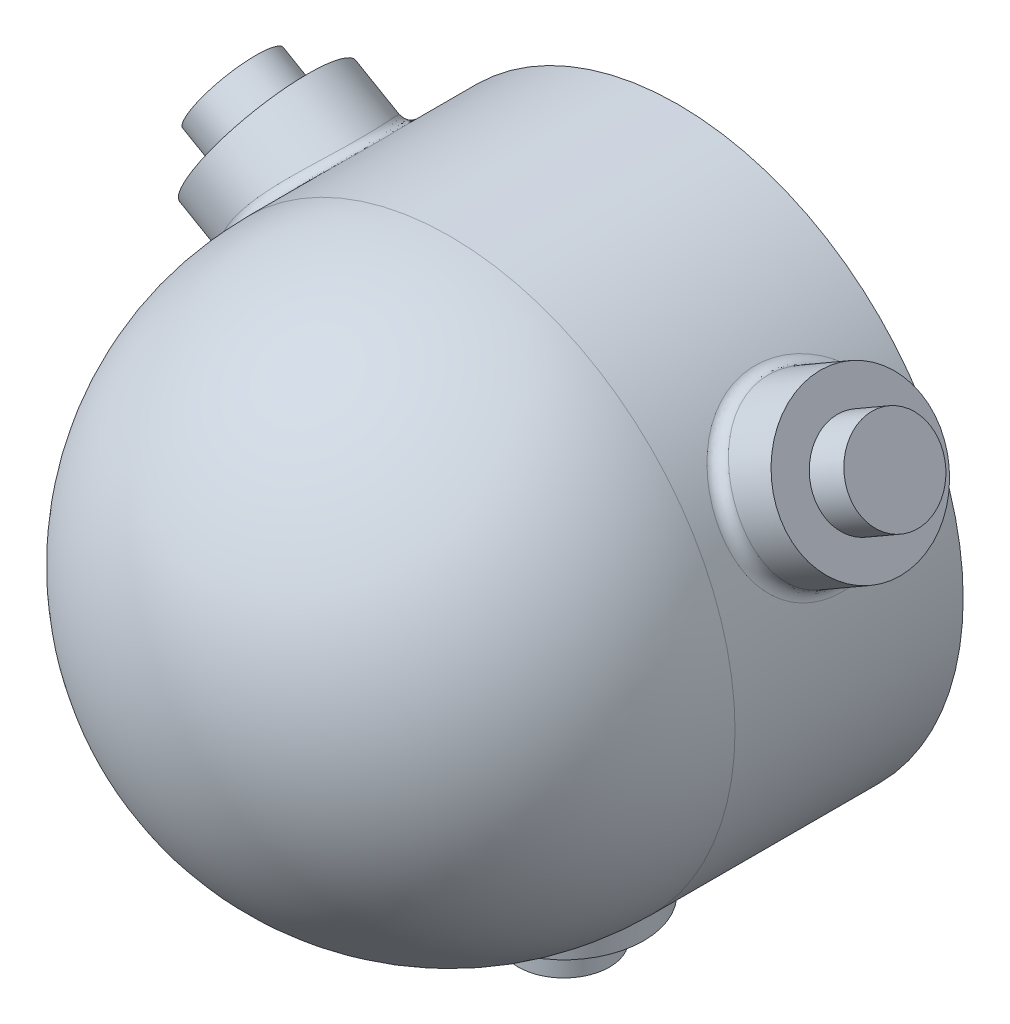
from build123d import *

# Parameters (mm, degrees)
SKETCH1_R           = 25
BOSS_EXTRUDE1_DEPTH = 20
SKETCH2_R           = 7
BOSS_EXTRUDE4_DEPTH = 5
SKETCH5_R           = 12.5
CUT_EXTRUDE2_DEPTH  = 10
REVOLVE1_ANGLE      = 180
SKETCH7_R           = 4
BOSS_EXTRUDE5_DEPTH = 3.5
CIRPATTERN1_COUNT   = 3
FILLET1_R           = 1
FILLET2_R           = 1
FILLET3_R           = 1


with BuildPart() as part:
    # Sketch1 → Boss-Extrude1 (new body)
    with BuildSketch(Plane.XY):
        Circle(SKETCH1_R)
    extrude(amount=BOSS_EXTRUDE1_DEPTH)

    # Sketch2 → Boss-Extrude4 (add, symmetric)
    with BuildSketch(Plane(origin=(-21.650635095, 12.5, 0), x_dir=(0, 0, -1), z_dir=(-0.866025404, 0.5, 0))):
        with Locations((-10, 0)):
            Circle(SKETCH2_R)
    boss_extrude4 = extrude(amount=BOSS_EXTRUDE4_DEPTH, both=True)

    # Sketch5 → Cut-Extrude2 (cut)
    with BuildSketch(Plane(origin=(0, 0, 0), x_dir=(-1, 0, 0), z_dir=(0, 0, -1))):
        Circle(SKETCH5_R)
    extrude(amount=-CUT_EXTRUDE2_DEPTH, mode=Mode.SUBTRACT)

    # Sketch6 → Revolve1 (revolve)
    with BuildSketch(Plane.XY.offset(20)):
        with BuildLine():
            Line((0, -25), (0, 25))
            ThreePointArc((0, 25), (-17.67766953, 17.67766953), (-25, 0))
            ThreePointArc((-25, 0), (-17.67766953, -17.67766953), (0, -25))
        make_face()
    revolve(axis=Axis((0, -25, 20), (0, 1, 0)), revolution_arc=REVOLVE1_ANGLE)

    # Sketch7 → Boss-Extrude5 (add)
    with BuildSketch(Plane(origin=(-25.980762114, 15, 0), x_dir=(0, 0, 1), z_dir=(-0.866025404, 0.5, 0))):
        with Locations((10, 0)):
            Circle(SKETCH7_R)
    boss_extrude5 = extrude(amount=BOSS_EXTRUDE5_DEPTH)

    # CirPattern1: Boss-Extrude4, Boss-Extrude5 ×3 about axis
    cirpattern1_axis = Axis((0, 0, 0), (0, 0, 1))
    for i in range(1, CIRPATTERN1_COUNT):
        add(boss_extrude4.rotate(cirpattern1_axis, i * 360 / CIRPATTERN1_COUNT))
        add(boss_extrude5.rotate(cirpattern1_axis, i * 360 / CIRPATTERN1_COUNT))

    # Fillet1
    fillet1_edges = [part.edges().sort_by_distance(p)[0] for p in [
        (21.650635066, 12.499999983, 17.000000008),
    ]]
    fillet(fillet1_edges, radius=FILLET1_R)

    # Fillet2
    fillet2_edges = [part.edges().sort_by_distance(p)[0] for p in [
        (-21.650635066, 12.499999983, 17.000000008),
    ]]
    fillet(fillet2_edges, radius=FILLET2_R)

    # Fillet3
    fillet3_edges = [part.edges().sort_by_distance(p)[0] for p in [
        (0, -24.999999967, 17.000000008),
    ]]
    fillet(fillet3_edges, radius=FILLET3_R)


solid = part.part
